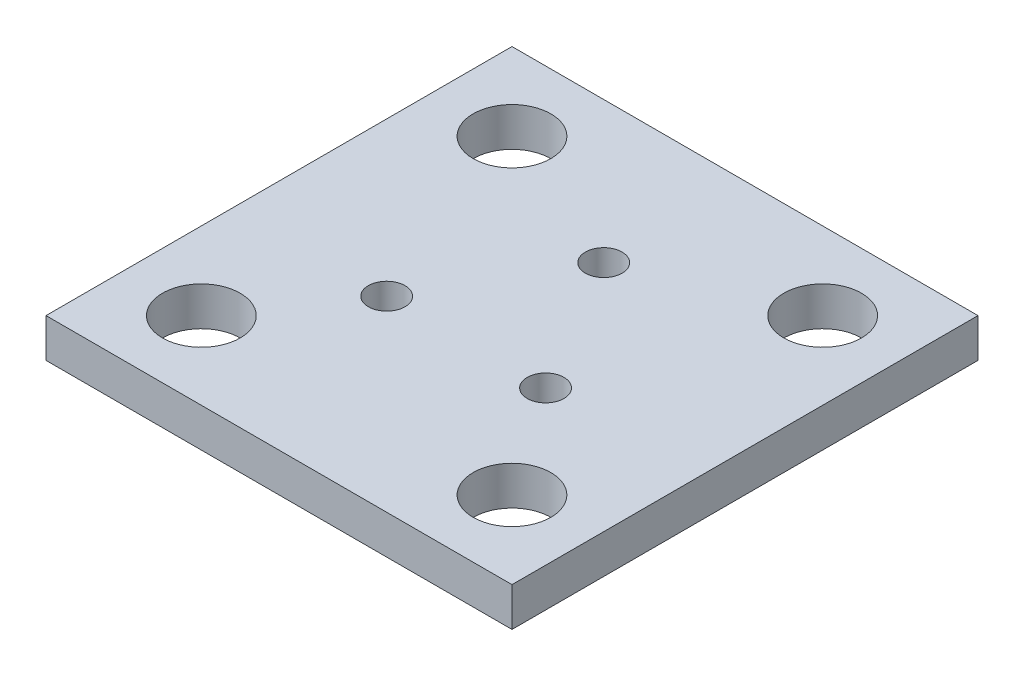
from build123d import *

# Parameters (mm, degrees)
SKETCH1_W           = 38.1
SKETCH1_H           = 38.1
BOSS_EXTRUDE1_DEPTH = 3.175
SKETCH2_R           = 1.5
CUT_EXTRUDE1_DEPTH  = 4.175
SKETCH3_R           = 3.175
CUT_EXTRUDE2_DEPTH  = 4.175


with BuildPart() as part:
    # Sketch1 → Boss-Extrude1 (new body)
    with BuildSketch(Plane(origin=(0, 0, 0), x_dir=(1, 0, 0), z_dir=(0, 1, 0))):
        Rectangle(SKETCH1_W, SKETCH1_H)
    extrude(amount=BOSS_EXTRUDE1_DEPTH)

    # Sketch2 → Cut-Extrude1 (cut, through all)
    with BuildSketch(Plane(origin=(0, 3.175, 0), x_dir=(1, 0, 0), z_dir=(0, 1, 0))):
        with Locations((0, 7.5)):
            Circle(SKETCH2_R)
        with Locations((6.495190528, -3.75)):
            Circle(SKETCH2_R)
        with Locations((-6.495190528, -3.75)):
            Circle(SKETCH2_R)
    extrude(amount=-CUT_EXTRUDE1_DEPTH, mode=Mode.SUBTRACT)

    # Sketch3 → Cut-Extrude2 (cut, through all)
    with BuildSketch(Plane(origin=(0, 3.175, 0), x_dir=(1, 0, 0), z_dir=(0, 1, 0))):
        with Locations((-12.7, 12.7)):
            Circle(SKETCH3_R)
        with Locations((-12.7, -12.7)):
            Circle(SKETCH3_R)
        with Locations((12.7, -12.7)):
            Circle(SKETCH3_R)
        with Locations((12.7, 12.7)):
            Circle(SKETCH3_R)
    extrude(amount=-CUT_EXTRUDE2_DEPTH, mode=Mode.SUBTRACT)


solid = part.part
